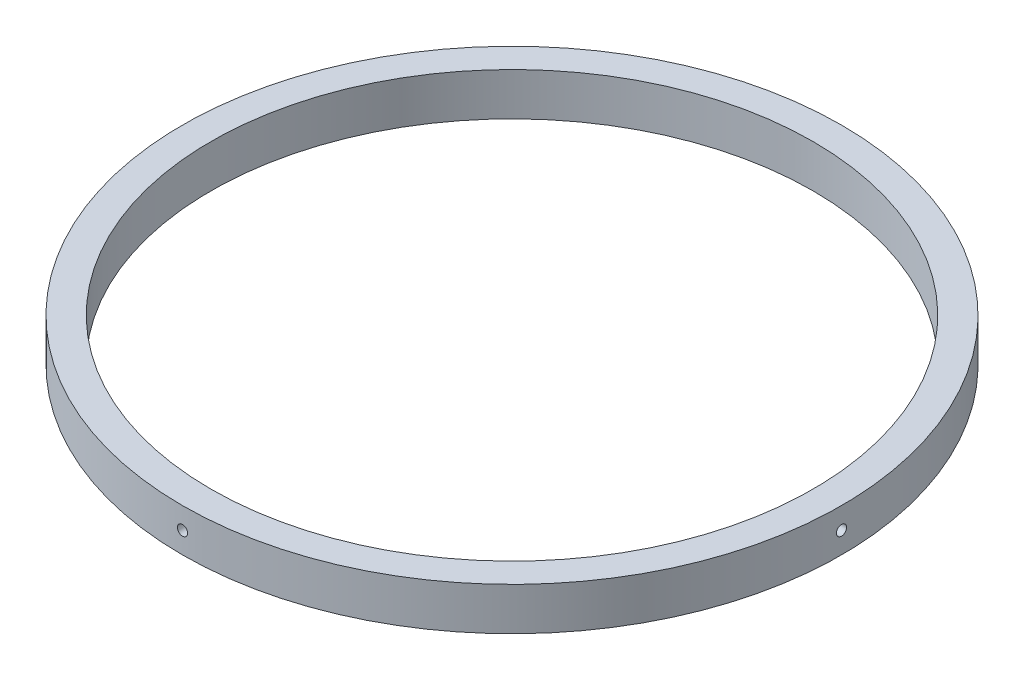
from build123d import *

# Parameters (mm, degrees)
SKETCH1_R           = 73.4441
SKETCH1_R_2         = 67.0941
BOSS_EXTRUDE1_DEPTH = 9.525
CIRPATTERN1_COUNT   = 4


with BuildPart() as part:
    # Sketch1 → Boss-Extrude1 (new body)
    with BuildSketch(Plane(origin=(0, 0, 0), x_dir=(1, 0, 0), z_dir=(0, 1, 0))):
        Circle(SKETCH1_R)
        Circle(SKETCH1_R_2, mode=Mode.SUBTRACT)
    extrude(amount=BOSS_EXTRUDE1_DEPTH)

    # Sketch3 → Tap Drill for #4-40 Tap1 (revolve, cut)
    with BuildSketch(Plane(origin=(0, 4.7625, 73.4441), x_dir=(0, -1, 0), z_dir=(1, 0, 0))):
        Polygon((0, 0), (0, 5.441652758), (1.1303, 4.7625), (1.1303, 0), align=None)
    tap_drill_for_4_40_tap1 = revolve(axis=Axis((0, 4.7625, 79.7941), (0, 0, -1)), mode=Mode.SUBTRACT)

    # CirPattern1: Tap Drill for #4-40 Tap1 ×4 about axis
    cirpattern1_axis = Axis((0, 9.525, 0), (0, 1, 0))
    for i in range(1, CIRPATTERN1_COUNT):
        add(tap_drill_for_4_40_tap1.rotate(cirpattern1_axis, i * 360 / CIRPATTERN1_COUNT), mode=Mode.SUBTRACT)


solid = part.part
